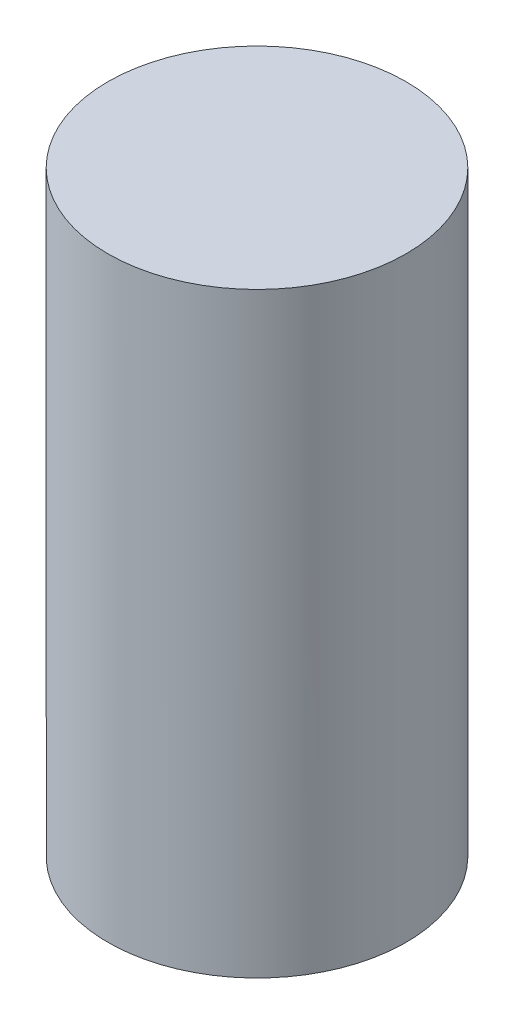
from build123d import *

# Parameters (mm, degrees)
SKETCH1_R           = 0.375
BOSS_EXTRUDE1_DEPTH = 0.125
SKETCH2_R           = 0.375
BOSS_EXTRUDE2_DEPTH = 0.625
SKETCH3_R           = 0.375
BOSS_EXTRUDE3_DEPTH = 0.625


with BuildPart() as part:
    # Sketch1 → Boss-Extrude1 (new body, symmetric)
    with BuildSketch(Plane(origin=(0, 0, 0), x_dir=(1, 0, 0), z_dir=(0, 1, 0))):
        Circle(SKETCH1_R)
    extrude(amount=BOSS_EXTRUDE1_DEPTH, both=True)

    # Sketch2 → Boss-Extrude2 (add)
    with BuildSketch(Plane(origin=(0, 0.125, 0), x_dir=(1, 0, 0), z_dir=(0, 1, 0))):
        Circle(SKETCH2_R)
    extrude(amount=BOSS_EXTRUDE2_DEPTH)

    # Sketch3 → Boss-Extrude3 (add)
    with BuildSketch(Plane.XZ.offset(0.125)):
        Circle(SKETCH3_R)
    extrude(amount=BOSS_EXTRUDE3_DEPTH)


solid = part.part
